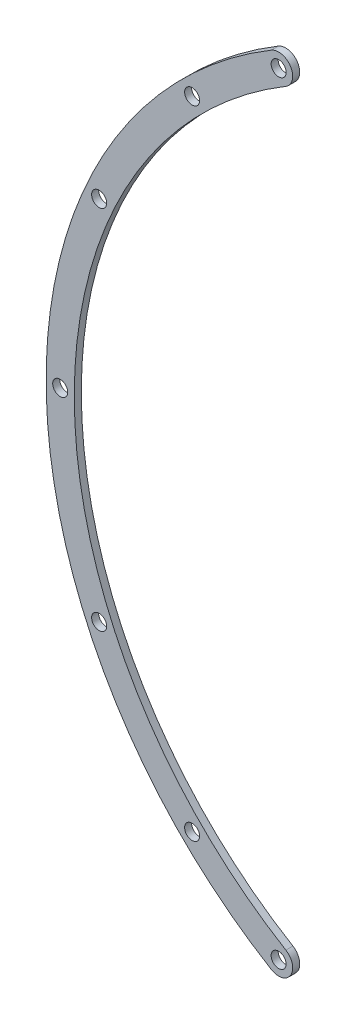
from build123d import *

# Parameters (mm, degrees)
SKETCH1_R            = 1.4
SKETCH1_R_2          = 1.6
SKETCH1_R_3          = 56
BOSS_EXTRUDE2_DEPTH  = 1.5
BOSS_EXTRUDE3_DEPTH  = 1.5
SKETCH3_R            = 1.6
CUT_EXTRUDE1_DEPTH   = 10
SKETCH4_R            = 1.6
BOSS_EXTRUDE4_DEPTH  = 1.5
FILLET1_R            = 3
SKETCH5_R            = 1.6
BOSS_EXTRUDE5_DEPTH  = 1.5
SKETCH6_R            = 1.6
CUT_EXTRUDE2_DEPTH   = 1.5
CUT_EXTRUDE3_DEPTH   = 10
SKETCH8_R            = 1.4
BOSS_EXTRUDE6_DEPTH  = 1.5
SKETCH9_W            = 144
SKETCH9_H            = 6
BOSS_EXTRUDE7_DEPTH  = 1.5
BOSS_EXTRUDE8_DEPTH  = 1.5
SKETCH11_W           = 71.777589622
SKETCH11_H           = 10.305965164
CUT_EXTRUDE4_DEPTH   = 41
SKETCH12_W           = 71.777589622
SKETCH12_H           = 6
BOSS_EXTRUDE9_DEPTH  = 1.5
SKETCH13_W           = 6
SKETCH13_H           = 51.475780146
SKETCH13_H_2         = 46.82423944
BOSS_EXTRUDE10_DEPTH = 1.5
SKETCH14_W           = 66
SKETCH14_H           = 6
CUT_EXTRUDE5_DEPTH   = 41
BOSS_EXTRUDE11_DEPTH = 1.5
SKETCH16_R           = 1.6
CUT_EXTRUDE6_DEPTH   = 5
SKETCH17_R           = 1.6
CUT_EXTRUDE7_DEPTH   = 5
SKETCH18_R           = 1.6
BOSS_EXTRUDE14_DEPTH = 1.5
BOSS_EXTRUDE15_DEPTH = 1.5
SKETCH21_W           = 1.5
SKETCH21_H           = 32.106154556
BOSS_EXTRUDE16_DEPTH = 1.5
SKETCH22_R           = 1.6
SKETCH22_R_2         = 1.7
CUT_EXTRUDE9_DEPTH   = 1.5
BOSS_EXTRUDE17_DEPTH = 1.5
SKETCH24_R           = 1.6
CUT_EXTRUDE10_DEPTH  = 1.5
SKETCH25_R           = 1.6
BOSS_EXTRUDE18_DEPTH = 1.5
SKETCH26_R           = 1.6
CUT_EXTRUDE11_DEPTH  = 1.5
SKETCH28_R           = 1.6
CUT_EXTRUDE12_DEPTH  = 1.5
SKETCH29_R           = 1.6
BOSS_EXTRUDE19_DEPTH = 1.5
SKETCH30_W           = 4.95
SKETCH30_H           = 32.106154556
SKETCH30_W_2         = 1.5
CUT_EXTRUDE13_DEPTH  = 1.5
BOSS_EXTRUDE20_DEPTH = 1.5
SKETCH32_R           = 1.6
BOSS_EXTRUDE21_DEPTH = 1.5
CUT_EXTRUDE14_DEPTH  = 10
SKETCH34_R           = 1.6
CUT_EXTRUDE15_DEPTH  = 10


with BuildPart() as part:
    # Sketch1 → Boss-Extrude2 (new body)
    with BuildSketch(Plane.XY):
        with BuildLine():
            Line((-35.888794811, 73.41211972), (-35.888794811, 92.265889727))
            ThreePointArc((-35.888794811, 92.265889727), (-42.061063674, 89.620683565), (-48.039811225, 86.563136135))
            Line((-48.039811225, 86.563136135), (-41.888794811, 80.41211972))
            Line((-41.888794811, 80.41211972), (-41.888794811, 65.59143593))
            Line((-41.888794811, 65.59143593), (-53.74011537, 53.74011537))
            Line((-53.74011537, 53.74011537), (-65.053823869, 42.426406871))
            Line((-65.053823869, 42.426406871), (-71.46564447, 36.01458627))
            Line((-71.46564447, 36.01458627), (-82.641648571, 47.190590371))
            ThreePointArc((-82.641648571, 47.190590371), (-85.206397148, 48.036317618), (-87.411811693, 46.477684716))
            ThreePointArc((-87.411811693, 46.477684716), (-99, 0), (-87.411811693, -46.477684716))
            ThreePointArc((-87.411811693, -46.477684716), (-85.206397148, -48.036317618), (-82.641648571, -47.190590371))
            Line((-82.641648571, -47.190590371), (-71.46564447, -36.01458627))
            Line((-71.46564447, -36.01458627), (-65.053823869, -42.426406871))
            Line((-65.053823869, -42.426406871), (-53.74011537, -53.74011537))
            Line((-53.74011537, -53.74011537), (-41.888794811, -65.59143593))
            Line((-41.888794811, -65.59143593), (-41.888794811, -80.41211972))
            Line((-41.888794811, -80.41211972), (-48.039811225, -86.563136135))
            ThreePointArc((-48.039811225, -86.563136135), (-42.061063674, -89.620683565), (-35.888794811, -92.265889727))
            Line((-35.888794811, -92.265889727), (-35.888794811, -73.41211972))
            Line((-35.888794811, -73.41211972), (35.888794811, -73.41211972))
            Line((35.888794811, -73.41211972), (35.888794811, -92.265889727))
            ThreePointArc((35.888794811, -92.265889727), (42.061063674, -89.620683565), (48.039811225, -86.563136135))
            Line((48.039811225, -86.563136135), (41.888794811, -80.41211972))
            Line((41.888794811, -80.41211972), (41.888794811, -65.59143593))
            Line((41.888794811, -65.59143593), (53.74011537, -53.74011537))
            Line((53.74011537, -53.74011537), (65.053823869, -42.426406871))
            Line((65.053823869, -42.426406871), (71.46564447, -36.01458627))
            Line((71.46564447, -36.01458627), (82.641648571, -47.190590371))
            ThreePointArc((82.641648571, -47.190590371), (85.206397148, -48.036317618), (87.411811693, -46.477684716))
            ThreePointArc((87.411811693, -46.477684716), (99, 0), (87.411811693, 46.477684716))
            ThreePointArc((87.411811693, 46.477684716), (85.206397148, 48.036317618), (82.641648571, 47.190590371))
            Line((82.641648571, 47.190590371), (71.46564447, 36.01458627))
            Line((71.46564447, 36.01458627), (65.053823869, 42.426406871))
            Line((65.053823869, 42.426406871), (53.74011537, 53.74011537))
            Line((53.74011537, 53.74011537), (41.888794811, 65.59143593))
            Line((41.888794811, 65.59143593), (41.888794811, 80.41211972))
            Line((41.888794811, 80.41211972), (48.039811225, 86.563136135))
            ThreePointArc((48.039811225, 86.563136135), (42.061063674, 89.620683565), (35.888794811, 92.265889727))
            Line((35.888794811, 92.265889727), (35.888794811, 73.41211972))
            Line((35.888794811, 73.41211972), (-35.888794811, 73.41211972))
        make_face()
        with Locations((-36.062445841, 54.447222151)):
            Circle(SKETCH1_R, mode=Mode.SUBTRACT)
        with Locations((-54.447222151, 36.062445841)):
            Circle(SKETCH1_R, mode=Mode.SUBTRACT)
        with Locations((-60.104076401, 41.71930009)):
            Circle(SKETCH1_R, mode=Mode.SUBTRACT)
        with Locations((-41.71930009, 60.104076401)):
            Circle(SKETCH1_R, mode=Mode.SUBTRACT)
        with Locations((41.365746699, 41.365746699)):
            Circle(SKETCH1_R_2, mode=Mode.SUBTRACT)
        with Locations((41.71930009, 60.104076401)):
            Circle(SKETCH1_R, mode=Mode.SUBTRACT)
        with Locations((60.104076401, 41.71930009)):
            Circle(SKETCH1_R, mode=Mode.SUBTRACT)
        with Locations((54.447222151, 36.062445841)):
            Circle(SKETCH1_R, mode=Mode.SUBTRACT)
        Circle(SKETCH1_R_3, mode=Mode.SUBTRACT)
        with Locations((36.062445841, 54.447222151)):
            Circle(SKETCH1_R, mode=Mode.SUBTRACT)
        with Locations((-40.571353127, 87.005547556)):
            Circle(SKETCH1_R_2, mode=Mode.SUBTRACT)
        with Locations((40.571353127, -87.005547556)):
            Circle(SKETCH1_R_2, mode=Mode.SUBTRACT)
        with Locations((-40.571353127, -87.005547556)):
            Circle(SKETCH1_R_2, mode=Mode.SUBTRACT)
        with Locations((41.365746699, -41.365746699)):
            Circle(SKETCH1_R_2, mode=Mode.SUBTRACT)
        with Locations((-41.365746699, 41.365746699)):
            Circle(SKETCH1_R_2, mode=Mode.SUBTRACT)
        with Locations((-84.762968914, 45.069270027)):
            Circle(SKETCH1_R_2, mode=Mode.SUBTRACT)
        with Locations((-41.365746699, -41.365746699)):
            Circle(SKETCH1_R_2, mode=Mode.SUBTRACT)
        with Locations((84.762968914, 45.069270027)):
            Circle(SKETCH1_R_2, mode=Mode.SUBTRACT)
        with Locations((40.571353127, 87.005547556)):
            Circle(SKETCH1_R_2, mode=Mode.SUBTRACT)
        with Locations((36.062445841, -54.447222151)):
            Circle(SKETCH1_R, mode=Mode.SUBTRACT)
        with Locations((54.447222151, -36.062445841)):
            Circle(SKETCH1_R, mode=Mode.SUBTRACT)
        with Locations((60.104076401, -41.71930009)):
            Circle(SKETCH1_R, mode=Mode.SUBTRACT)
        with Locations((41.71930009, -60.104076401)):
            Circle(SKETCH1_R, mode=Mode.SUBTRACT)
        with Locations((-41.71930009, -60.104076401)):
            Circle(SKETCH1_R, mode=Mode.SUBTRACT)
        with Locations((-60.104076401, -41.71930009)):
            Circle(SKETCH1_R, mode=Mode.SUBTRACT)
        with Locations((-54.447222151, -36.062445841)):
            Circle(SKETCH1_R, mode=Mode.SUBTRACT)
        with Locations((-36.062445841, -54.447222151)):
            Circle(SKETCH1_R, mode=Mode.SUBTRACT)
        with Locations((84.762968914, -45.069270027)):
            Circle(SKETCH1_R_2, mode=Mode.SUBTRACT)
        with Locations((-84.762968914, -45.069270027)):
            Circle(SKETCH1_R_2, mode=Mode.SUBTRACT)
        with BuildLine():
            Line((-56.568542495, 42.426406871), (-49.621038435, 35.478902811))
            ThreePointArc((-49.621038435, 35.478902811), (-43.133513652, 43.133513652), (-35.478902811, 49.621038435))
            Line((-35.478902811, 49.621038435), (-42.426406871, 56.568542495))
            Line((-42.426406871, 56.568542495), (-56.568542495, 42.426406871))
        make_face(mode=Mode.SUBTRACT)
        with BuildLine():
            Line((-57.337431152, 34.710014154), (-52.937019276, 30.309602278))
            ThreePointArc((-52.937019276, 30.309602278), (-61, 0), (-52.937019276, -30.309602278))
            Line((-52.937019276, -30.309602278), (-57.337431152, -34.710014154))
            Line((-57.337431152, -34.710014154), (-60.811183182, -38.183766184))
            Line((-60.811183182, -38.183766184), (-71.46564447, -27.529304896))
            Line((-71.46564447, -27.529304896), (-83.951228087, -40.014888513))
            ThreePointArc((-83.951228087, -40.014888513), (-93, 0), (-83.951228087, 40.014888513))
            Line((-83.951228087, 40.014888513), (-71.46564447, 27.529304896))
            Line((-71.46564447, 27.529304896), (-60.811183182, 38.183766184))
            Line((-60.811183182, 38.183766184), (-57.337431152, 34.710014154))
        make_face(mode=Mode.SUBTRACT)
        with BuildLine():
            Line((-35.888794811, 67.41211972), (-35.888794811, 58.516211808))
            Line((-35.888794811, 58.516211808), (-30.309602278, 52.937019275))
            ThreePointArc((-30.309602278, 52.937019275), (0, 61), (30.309602278, 52.937019275))
            Line((30.309602278, 52.937019275), (35.888794811, 58.516211808))
            Line((35.888794811, 58.516211808), (35.888794811, 67.41211972))
            Line((35.888794811, 67.41211972), (0, 67.41211972))
            Line((0, 67.41211972), (-35.888794811, 67.41211972))
        make_face(mode=Mode.SUBTRACT)
        with BuildLine():
            Line((60.811183182, 38.183766184), (71.46564447, 27.529304896))
            Line((71.46564447, 27.529304896), (83.951228087, 40.014888513))
            ThreePointArc((83.951228087, 40.014888513), (93, 0), (83.951228087, -40.014888513))
            Line((83.951228087, -40.014888513), (71.46564447, -27.529304896))
            Line((71.46564447, -27.529304896), (60.811183182, -38.183766184))
            Line((60.811183182, -38.183766184), (57.337431152, -34.710014154))
            Line((57.337431152, -34.710014154), (52.937019276, -30.309602278))
            ThreePointArc((52.937019276, -30.309602278), (61, 0), (52.937019276, 30.309602278))
            Line((52.937019276, 30.309602278), (57.337431152, 34.710014154))
            Line((57.337431152, 34.710014154), (60.811183182, 38.183766184))
        make_face(mode=Mode.SUBTRACT)
        with BuildLine():
            Line((42.426406871, 56.568542495), (56.568542495, 42.426406871))
            Line((56.568542495, 42.426406871), (49.621038435, 35.478902811))
            ThreePointArc((49.621038435, 35.478902811), (43.133513652, 43.133513652), (35.478902811, 49.621038435))
            Line((35.478902811, 49.621038435), (42.426406871, 56.568542495))
        make_face(mode=Mode.SUBTRACT)
        with BuildLine():
            Line((0, -67.41211972), (35.888794811, -67.41211972))
            Line((35.888794811, -67.41211972), (35.888794811, -58.516211808))
            Line((35.888794811, -58.516211808), (30.309602278, -52.937019275))
            ThreePointArc((30.309602278, -52.937019275), (0, -61), (-30.309602278, -52.937019275))
            Line((-30.309602278, -52.937019275), (-35.888794811, -58.516211808))
            Line((-35.888794811, -58.516211808), (-35.888794811, -67.41211972))
            Line((-35.888794811, -67.41211972), (0, -67.41211972))
        make_face(mode=Mode.SUBTRACT)
        with BuildLine():
            Line((56.568542495, -42.426406871), (49.621038435, -35.478902811))
            ThreePointArc((49.621038435, -35.478902811), (43.133513652, -43.133513652), (35.478902811, -49.621038435))
            Line((35.478902811, -49.621038435), (42.426406871, -56.568542495))
            Line((42.426406871, -56.568542495), (56.568542495, -42.426406871))
        make_face(mode=Mode.SUBTRACT)
        with BuildLine():
            Line((-42.426406871, -56.568542495), (-56.568542495, -42.426406871))
            Line((-56.568542495, -42.426406871), (-49.621038435, -35.478902811))
            ThreePointArc((-49.621038435, -35.478902811), (-43.133513652, -43.133513652), (-35.478902811, -49.621038435))
            Line((-35.478902811, -49.621038435), (-42.426406871, -56.568542495))
        make_face(mode=Mode.SUBTRACT)
    extrude(amount=BOSS_EXTRUDE2_DEPTH)

    # Sketch2 → Boss-Extrude3 (add)
    with BuildSketch(Plane.XY.offset(1.5)):
        with BuildLine():
            Line((-41.888794811, 80.41211972), (-41.888794811, 78.41211972))
            Line((-41.888794811, 78.41211972), (-49.31800671, 85.841331619))
            ThreePointArc((-49.31800671, 85.841331619), (-47.440229793, 86.893179233), (-45.540030314, 87.903956902))
            Line((-45.540030314, 87.903956902), (-41.888794811, 84.252721398))
            Line((-41.888794811, 84.252721398), (-41.888794811, 80.41211972))
        make_face()
        with BuildLine():
            Line((41.888794811, 84.252721398), (45.540030314, 87.903956902))
            ThreePointArc((45.540030314, 87.903956902), (47.440229793, 86.893179233), (49.31800671, 85.841331619))
            Line((49.31800671, 85.841331619), (41.888794811, 78.41211972))
            Line((41.888794811, 78.41211972), (41.888794811, 80.41211972))
            Line((41.888794811, 80.41211972), (41.888794811, 84.252721398))
        make_face()
        with BuildLine():
            Line((41.888794811, -80.41211972), (41.888794811, -78.41211972))
            Line((41.888794811, -78.41211972), (49.31800671, -85.841331619))
            ThreePointArc((49.31800671, -85.841331619), (47.440229793, -86.893179233), (45.540030314, -87.903956902))
            Line((45.540030314, -87.903956902), (41.888794811, -84.252721398))
            Line((41.888794811, -84.252721398), (41.888794811, -80.41211972))
        make_face()
        with BuildLine():
            Line((-41.888794811, -84.252721398), (-45.540030314, -87.903956902))
            ThreePointArc((-45.540030314, -87.903956902), (-47.440229793, -86.893179233), (-49.31800671, -85.841331619))
            Line((-49.31800671, -85.841331619), (-41.888794811, -78.41211972))
            Line((-41.888794811, -78.41211972), (-41.888794811, -80.41211972))
            Line((-41.888794811, -80.41211972), (-41.888794811, -84.252721398))
        make_face()
    extrude(amount=-BOSS_EXTRUDE3_DEPTH)

    # Sketch3 → Cut-Extrude1 (cut)
    with BuildSketch(Plane.XY.offset(1.5)):
        with Locations((-44.327866871, 85.153039985)):
            Circle(SKETCH3_R)
        with Locations((44.327866871, 85.153039985)):
            Circle(SKETCH3_R)
        with Locations((44.327866871, -85.153039985)):
            Circle(SKETCH3_R)
        with Locations((-44.327866871, -85.153039985)):
            Circle(SKETCH3_R)
    extrude(amount=-CUT_EXTRUDE1_DEPTH, mode=Mode.SUBTRACT)

    # Sketch4 → Boss-Extrude4 (add)
    with BuildSketch(Plane.XY.offset(1.5)):
        with Locations((-40.571353127, 87.005547556)):
            Circle(SKETCH4_R)
        with Locations((40.571353127, 87.005547556)):
            Circle(SKETCH4_R)
        with Locations((40.571353127, -87.005547556)):
            Circle(SKETCH4_R)
        with Locations((-40.571353127, -87.005547556)):
            Circle(SKETCH4_R)
    extrude(amount=-BOSS_EXTRUDE4_DEPTH)

    # Fillet1
    fillet1_edges = [part.edges().sort_by_distance(p)[0] for p in [
        (35.888794811, -92.265889727, 0.75),
        (-35.888794811, -92.265889727, 0.75),
        (-35.888794811, 92.265889727, 0.75),
        (35.888794811, 92.265889727, 0.75),
        (49.31800671, 85.841331619, 0.75),
        (-49.31800671, 85.841331619, 0.75),
        (49.31800671, -85.841331619, 0.75),
        (-49.31800671, -85.841331619, 0.75),
    ]]
    fillet(fillet1_edges, radius=FILLET1_R)

    # Sketch5 → Boss-Extrude5 (add)
    with BuildSketch(Plane.XY.offset(1.5)):
        with BuildLine():
            ThreePointArc((-7, 66.41211972), (-10, 63.41211972), (-13, 66.41211972))
            Line((-13, 66.41211972), (-13, 67.41211972))
            Line((-13, 67.41211972), (-9.775161328, 70.187281048))
            Line((-9.775161328, 70.187281048), (-7, 67.41211972))
            Line((-7, 67.41211972), (-7, 66.41211972))
        make_face()
        with Locations((-10, 66.41211972)):
            Circle(SKETCH5_R, mode=Mode.SUBTRACT)
        with BuildLine():
            Line((7, 66.41211972), (7, 67.41211972))
            Line((7, 67.41211972), (9.775161328, 70.187281048))
            Line((9.775161328, 70.187281048), (13, 67.41211972))
            Line((13, 67.41211972), (13, 66.41211972))
            ThreePointArc((13, 66.41211972), (10, 63.41211972), (7, 66.41211972))
        make_face()
        with Locations((10, 66.41211972)):
            Circle(SKETCH5_R, mode=Mode.SUBTRACT)
        with BuildLine():
            ThreePointArc((7, -66.41211972), (10, -63.41211972), (13, -66.41211972))
            Line((13, -66.41211972), (13, -67.41211972))
            Line((13, -67.41211972), (9.775161328, -70.187281048))
            Line((9.775161328, -70.187281048), (7, -67.41211972))
            Line((7, -67.41211972), (7, -66.41211972))
        make_face()
        with Locations((10, -66.41211972)):
            Circle(SKETCH5_R, mode=Mode.SUBTRACT)
        with BuildLine():
            Line((-7, -66.41211972), (-7, -67.41211972))
            Line((-7, -67.41211972), (-9.775161328, -70.187281048))
            Line((-9.775161328, -70.187281048), (-13, -67.41211972))
            Line((-13, -67.41211972), (-13, -66.41211972))
            ThreePointArc((-13, -66.41211972), (-10, -63.41211972), (-7, -66.41211972))
        make_face()
        with Locations((-10, -66.41211972)):
            Circle(SKETCH5_R, mode=Mode.SUBTRACT)
    extrude(amount=-BOSS_EXTRUDE5_DEPTH)

    # Sketch6 → Cut-Extrude2 (cut)
    with BuildSketch(Plane.XY.offset(1.5)):
        with Locations((-10, -66.41211972)):
            Circle(SKETCH6_R)
        with Locations((10, -66.41211972)):
            Circle(SKETCH6_R)
        with Locations((10, 66.41211972)):
            Circle(SKETCH6_R)
        with Locations((-10, 66.41211972)):
            Circle(SKETCH6_R)
    extrude(amount=-CUT_EXTRUDE2_DEPTH, mode=Mode.SUBTRACT)

    # Sketch7 → Cut-Extrude3 (cut)
    with BuildSketch(Plane.XY.offset(1.5)):
        Polygon((-71.46564447, 27.529304896), (-31.582829646, 67.41211972), (31.582829646, 67.41211972), (71.46564447, 27.529304896), (71.46564447, -27.529304896), (31.582829646, -67.41211972), (-31.582829646, -67.41211972), (-71.46564447, -27.529304896), align=None)
    extrude(amount=-CUT_EXTRUDE3_DEPTH, mode=Mode.SUBTRACT)

    # Sketch8 → Boss-Extrude6 (add)
    with BuildSketch(Plane.XY.offset(1.5)):
        with Locations((-60.104076401, -41.71930009)):
            Circle(SKETCH8_R)
        with Locations((-41.71930009, -60.104076401)):
            Circle(SKETCH8_R)
        with Locations((-60.104076401, 41.71930009)):
            Circle(SKETCH8_R)
        with Locations((-41.71930009, 60.104076401)):
            Circle(SKETCH8_R)
        with Locations((41.71930009, 60.104076401)):
            Circle(SKETCH8_R)
        with Locations((60.104076401, 41.71930009)):
            Circle(SKETCH8_R)
        with Locations((60.104076401, -41.71930009)):
            Circle(SKETCH8_R)
        with Locations((41.71930009, -60.104076401)):
            Circle(SKETCH8_R)
        Polygon((-23.568897205, -67.41211972), (23.568897205, -67.41211972), (18.047381119, -71.229666129), (-16.662853075, -71.229666129), align=None)
        Polygon((23.568897205, 67.41211972), (-26.29313108, 67.41211972), (-20.11587514, 71.683041123), (11.2489996, 71.683041123), align=None)
    extrude(amount=-BOSS_EXTRUDE6_DEPTH)

    # Sketch9 → Boss-Extrude7 (add)
    with BuildSketch(Plane.XY.offset(1.5)):
        with Locations((0, 26.41211972)):
            Rectangle(SKETCH9_W, SKETCH9_H)
        with Locations((0, -26.41211972)):
            Rectangle(SKETCH9_W, SKETCH9_H)
    extrude(amount=-BOSS_EXTRUDE7_DEPTH)

    # Sketch10 → Boss-Extrude8 (add)
    with BuildSketch(Plane.XY.offset(1.5)):
        Polygon((-72, 23.41211972), (-66, 23.41211972), (-66, 35.490217447), (-72, 28.063660426), align=None)
        Polygon((72, 28.063660426), (72, 23.41211972), (66, 23.41211972), (66, 35.490217447), align=None)
        Polygon((72, -23.41211972), (66, -23.41211972), (66, -35.490217447), (72, -28.063660426), align=None)
        Polygon((-72, -28.063660426), (-72, -23.41211972), (-66, -23.41211972), (-66, -35.490217447), align=None)
    extrude(amount=-BOSS_EXTRUDE8_DEPTH)

    # Sketch11 → Cut-Extrude4 (cut)
    with BuildSketch(Plane.XY.offset(1.5)):
        with Locations((0, 68.259137138)):
            Rectangle(SKETCH11_W, SKETCH11_H)
        with Locations((0, -68.259137138)):
            Rectangle(SKETCH11_W, SKETCH11_H)
    extrude(amount=-CUT_EXTRUDE4_DEPTH, mode=Mode.SUBTRACT)

    # Sketch12 → Boss-Extrude9 (add)
    with BuildSketch(Plane.XY.offset(1.5)):
        with Locations((0, 66.106154556)):
            Rectangle(SKETCH12_W, SKETCH12_H)
        with Locations((0, -66.106154556)):
            Rectangle(SKETCH12_W, SKETCH12_H)
    extrude(amount=-BOSS_EXTRUDE9_DEPTH)

    # Sketch13 → Boss-Extrude10 (add)
    with BuildSketch(Plane.XY.offset(1.5)):
        with Locations((-69, -2.325770353)):
            Rectangle(SKETCH13_W, SKETCH13_H)
        with Locations((69, 0)):
            Rectangle(SKETCH13_W, SKETCH13_H_2)
    extrude(amount=-BOSS_EXTRUDE10_DEPTH)

    # Sketch14 → Cut-Extrude5 (cut)
    with BuildSketch(Plane.XY.offset(1.5)):
        with Locations((33, 26.41211972)):
            Rectangle(SKETCH14_W, SKETCH14_H)
        with Locations((-33, 26.41211972)):
            Rectangle(SKETCH14_W, SKETCH14_H)
        with Locations((-33, -26.41211972)):
            Rectangle(SKETCH14_W, SKETCH14_H)
        with Locations((33, -26.41211972)):
            Rectangle(SKETCH14_W, SKETCH14_H)
    extrude(amount=-CUT_EXTRUDE5_DEPTH, mode=Mode.SUBTRACT)

    # Sketch15 → Boss-Extrude11 (add)
    with BuildSketch(Plane.XY.offset(1.5)):
        Polygon((-66, -25), (0, -25), (66, -25), (66, -31), (-66, -31), align=None)
        Polygon((0, 25), (66, 25), (66, 31), (-66, 31), (-66, 25), align=None)
    extrude(amount=-BOSS_EXTRUDE11_DEPTH)

    # Sketch16 → Cut-Extrude6 (cut)
    with BuildSketch(Plane.XY.offset(1.5)):
        with Locations((60, 28)):
            Circle(SKETCH16_R)
        with Locations((-60, 28)):
            Circle(SKETCH16_R)
        with Locations((-60, -28)):
            Circle(SKETCH16_R)
        with Locations((60, -28)):
            Circle(SKETCH16_R)
    extrude(amount=-CUT_EXTRUDE6_DEPTH, mode=Mode.SUBTRACT)

    # Sketch17 → Cut-Extrude7 (cut)
    with BuildSketch(Plane.XY.offset(1.5)):
        with Locations((-40, 28)):
            Circle(SKETCH17_R)
        with Locations((40, 28)):
            Circle(SKETCH17_R)
        with Locations((40, -28)):
            Circle(SKETCH17_R)
        with Locations((-40, -28)):
            Circle(SKETCH17_R)
    extrude(amount=-CUT_EXTRUDE7_DEPTH, mode=Mode.SUBTRACT)

    # Sketch18 → Boss-Extrude14 (add)
    with BuildSketch(Plane.XY.offset(1.5)):
        Polygon((34.5, 63.106154556), (34.5, 31), (31.5, 31), (28.5, 31), (28.5, 63.106154556), align=None)
        with Locations((31.5, 49)):
            Circle(SKETCH18_R, mode=Mode.SUBTRACT)
        with Locations((31.5, 39)):
            Circle(SKETCH18_R, mode=Mode.SUBTRACT)
        Polygon((-34.5, -63.106154556), (-34.5, -31), (-31.5, -31), (-28.5, -31), (-28.5, -63.106154556), align=None)
        with Locations((-31.5, -49)):
            Circle(SKETCH18_R, mode=Mode.SUBTRACT)
        with Locations((-31.5, -39)):
            Circle(SKETCH18_R, mode=Mode.SUBTRACT)
    extrude(amount=-BOSS_EXTRUDE14_DEPTH)

    # Sketch19 → Boss-Extrude15 (add)
    with BuildSketch(Plane.XY.offset(1.5)):
        Polygon((-38, 31), (-35, 31), (-35, 63.106154556), (-35.888794811, 63.106154556), (-41, 57.994949366), (-41, 31), align=None)
        with BuildLine():
            ThreePointArc((-36.4, 39), (-36.86862915, 37.86862915), (-38, 37.4))
            ThreePointArc((-38, 37.4), (-39.6, 39), (-38, 40.6))
            ThreePointArc((-38, 40.6), (-36.86862915, 40.13137085), (-36.4, 39))
        make_face(mode=Mode.SUBTRACT)
        with BuildLine():
            ThreePointArc((-36.4, 49), (-36.86862915, 47.86862915), (-38, 47.4))
            ThreePointArc((-38, 47.4), (-39.13137085, 50.13137085), (-36.4, 49))
        make_face(mode=Mode.SUBTRACT)
        Polygon((38, -31), (35, -31), (35, -63.106154556), (35.888794811, -63.106154556), (41, -57.994949366), (41, -31), align=None)
        with BuildLine():
            ThreePointArc((39.6, -49), (36.86862915, -50.13137085), (38, -47.4))
            ThreePointArc((38, -47.4), (39.13137085, -47.86862915), (39.6, -49))
        make_face(mode=Mode.SUBTRACT)
        with BuildLine():
            ThreePointArc((38, -40.6), (36.4, -39), (38, -37.4))
            ThreePointArc((38, -37.4), (39.13137085, -37.86862915), (39.6, -39))
            ThreePointArc((39.6, -39), (39.13137085, -40.13137085), (38, -40.6))
        make_face(mode=Mode.SUBTRACT)
    extrude(amount=-BOSS_EXTRUDE15_DEPTH)

    # Sketch21 → Boss-Extrude16 (add)
    with BuildSketch(Plane.XY.offset(1.5)):
        with BuildLine():
            ThreePointArc((-32.25, -40.413329403), (-31.4, -39), (-32.25, -37.586670597))
            ThreePointArc((-32.25, -37.586670597), (-29.9, -39), (-32.25, -40.413329403))
        make_face()
        with BuildLine():
            ThreePointArc((-32.25, -50.413329403), (-31.4, -49), (-32.25, -47.586670597))
            ThreePointArc((-32.25, -47.586670597), (-29.9, -49), (-32.25, -50.413329403))
        make_face()
        with Locations((-35.25, -47.053077278)):
            Rectangle(SKETCH21_W, SKETCH21_H)
        Polygon((42.5, -56.494949366), (41, -57.994949366), (41, -31), (42.5, -31), align=None)
        with BuildLine():
            ThreePointArc((38.75, -50.413329403), (36.4, -49), (38.75, -47.586670597))
            ThreePointArc((38.75, -47.586670597), (37.9, -49), (38.75, -50.413329403))
        make_face()
        with BuildLine():
            ThreePointArc((38.75, -40.413329403), (36.4, -39), (38.75, -37.586670597))
            ThreePointArc((38.75, -37.586670597), (37.9, -39), (38.75, -40.413329403))
        make_face()
        with Locations((35.25, 47.053077278)):
            Rectangle(SKETCH21_W, SKETCH21_H)
        with BuildLine():
            ThreePointArc((32.25, 47.586670597), (29.9, 49), (32.25, 50.413329403))
            ThreePointArc((32.25, 50.413329403), (31.4, 49), (32.25, 47.586670597))
        make_face()
        with BuildLine():
            ThreePointArc((32.25, 37.586670597), (29.9, 39), (32.25, 40.413329403))
            ThreePointArc((32.25, 40.413329403), (31.4, 39), (32.25, 37.586670597))
        make_face()
        with BuildLine():
            ThreePointArc((-38.75, 47.586670597), (-37.9, 49), (-38.75, 50.413329403))
            ThreePointArc((-38.75, 50.413329403), (-36.4, 49), (-38.75, 47.586670597))
        make_face()
        with BuildLine():
            ThreePointArc((-38.75, 37.586670597), (-37.9, 39), (-38.75, 40.413329403))
            ThreePointArc((-38.75, 40.413329403), (-36.4, 39), (-38.75, 37.586670597))
        make_face()
        Polygon((-41, 57.994949366), (-41, 31), (-42.5, 31), (-42.5, 56.494949366), align=None)
    extrude(amount=-BOSS_EXTRUDE16_DEPTH)

    # Sketch22 → Cut-Extrude9 (cut)
    with BuildSketch(Plane.XY.offset(1.5)):
        with Locations((-39.5, 49)):
            Circle(SKETCH22_R)
        with Locations((-39.6, 39)):
            Circle(SKETCH22_R_2)
        with Locations((33, 49)):
            Circle(SKETCH22_R)
        with Locations((33, 39)):
            Circle(SKETCH22_R)
        with Locations((-33, -39)):
            Circle(SKETCH22_R)
        with Locations((-33, -49)):
            Circle(SKETCH22_R)
        with Locations((39.5, -39)):
            Circle(SKETCH22_R)
        with Locations((39.5, -49)):
            Circle(SKETCH22_R)
    extrude(amount=-CUT_EXTRUDE9_DEPTH, mode=Mode.SUBTRACT)

    # Sketch23 → Boss-Extrude17 (add)
    with BuildSketch(Plane.XY.offset(1.5)):
        Polygon((36, 31), (39.45, 31), (39.45, 59.544949366), (36, 62.994949366), align=None)
        Polygon((-36, -31), (-39.45, -31), (-39.45, -59.544949366), (-36, -62.994949366), align=None)
    extrude(amount=-BOSS_EXTRUDE17_DEPTH)

    # Sketch24 → Cut-Extrude10 (cut)
    with BuildSketch(Plane.XY.offset(1.5)):
        with Locations((-36.45, -49)):
            Circle(SKETCH24_R)
        with Locations((-36.45, -39)):
            Circle(SKETCH24_R)
        with Locations((36.45, 49)):
            Circle(SKETCH24_R)
        with Locations((36.45, 39)):
            Circle(SKETCH24_R)
    extrude(amount=-CUT_EXTRUDE10_DEPTH, mode=Mode.SUBTRACT)

    # Sketch25 → Boss-Extrude18 (add)
    with BuildSketch(Plane.XY.offset(1.5)):
        with BuildLine():
            Line((-93.258777892, -26.525048498), (-91.439555948, -32.242603178))
            Line((-91.439555948, -32.242603178), (-87.090389028, -30.85877734))
            ThreePointArc((-87.090389028, -30.85877734), (-85.14122266, -27.090389028), (-88.909610972, -25.14122266))
            Line((-88.909610972, -25.14122266), (-93.258777892, -26.525048498))
        make_face()
        with Locations((-88, -28)):
            Circle(SKETCH25_R, mode=Mode.SUBTRACT)
        with BuildLine():
            Line((-87.090389028, 30.85877734), (-91.439555948, 32.242603178))
            Line((-91.439555948, 32.242603178), (-93.258777892, 26.525048498))
            Line((-93.258777892, 26.525048498), (-88.909610972, 25.14122266))
            ThreePointArc((-88.909610972, 25.14122266), (-85.14122266, 27.090389028), (-87.090389028, 30.85877734))
        make_face()
        with Locations((-88, 28)):
            Circle(SKETCH25_R, mode=Mode.SUBTRACT)
        with BuildLine():
            Line((87.090389028, -30.85877734), (91.439555948, -32.242603178))
            Line((91.439555948, -32.242603178), (93.258777892, -26.525048498))
            Line((93.258777892, -26.525048498), (88.909610972, -25.14122266))
            ThreePointArc((88.909610972, -25.14122266), (85.14122266, -27.090389028), (87.090389028, -30.85877734))
        make_face()
        with Locations((88, -28)):
            Circle(SKETCH25_R, mode=Mode.SUBTRACT)
        with BuildLine():
            Line((93.258777892, 26.525048498), (91.439555948, 32.242603178))
            Line((91.439555948, 32.242603178), (87.090389028, 30.85877734))
            ThreePointArc((87.090389028, 30.85877734), (85.14122266, 27.090389028), (88.909610972, 25.14122266))
            Line((88.909610972, 25.14122266), (93.258777892, 26.525048498))
        make_face()
        with Locations((88, 28)):
            Circle(SKETCH25_R, mode=Mode.SUBTRACT)
    extrude(amount=-BOSS_EXTRUDE18_DEPTH)

    # Sketch26 → Cut-Extrude11 (cut)
    with BuildSketch(Plane.XY.offset(1.5)):
        with Locations((-88, 28)):
            Circle(SKETCH26_R)
        with Locations((-88, -28)):
            Circle(SKETCH26_R)
        with Locations((88, -28)):
            Circle(SKETCH26_R)
        with Locations((88, 28)):
            Circle(SKETCH26_R)
    extrude(amount=-CUT_EXTRUDE11_DEPTH, mode=Mode.SUBTRACT)

    # Sketch28 → Cut-Extrude12 (cut)
    with BuildSketch(Plane.XY.offset(1.5)):
        with Locations((-87.700363934, 39.046717735)):
            Circle(SKETCH28_R)
        with Locations((87.700363934, 39.046717735)):
            Circle(SKETCH28_R)
        with Locations((87.700363934, -39.046717735)):
            Circle(SKETCH28_R)
        with Locations((-87.700363934, -39.046717735)):
            Circle(SKETCH28_R)
    extrude(amount=-CUT_EXTRUDE12_DEPTH, mode=Mode.SUBTRACT)

    # Sketch29 → Boss-Extrude19 (add)
    with BuildSketch(Plane.XY.offset(1.5)):
        with BuildLine():
            Line((42.598378746, 89.366538079), (38.032036127, 79.786872289))
            Line((38.032036127, 79.786872289), (41.393256923, 64.252993798))
            Line((41.393256923, 64.252993798), (46.575002765, 72.29639768))
            Line((46.575002765, 72.29639768), (51.939928592, 80.62414407))
            Line((51.939928592, 80.62414407), (51.990700761, 80.70295555))
            ThreePointArc((51.990700761, 80.70295555), (52.360123748, 82.991062404), (50.988769416, 84.85956277))
            ThreePointArc((50.988769416, 84.85956277), (46.847804451, 87.214008153), (42.598378746, 89.366538079))
        make_face()
        with Locations((44.327866871, 85.153039985)):
            Circle(SKETCH29_R, mode=Mode.SUBTRACT)
        with Locations((49.443655191, 82.288060867)):
            Circle(SKETCH29_R, mode=Mode.SUBTRACT)
        with BuildLine():
            ThreePointArc((-50.988769416, 84.85956277), (-52.360123748, 82.991062404), (-51.990700761, 80.70295555))
            Line((-51.990700761, 80.70295555), (-51.939928592, 80.62414407))
            Line((-51.939928592, 80.62414407), (-46.575002765, 72.29639768))
            Line((-46.575002765, 72.29639768), (-41.393256923, 64.252993798))
            Line((-41.393256923, 64.252993798), (-38.032036127, 79.786872289))
            Line((-38.032036127, 79.786872289), (-42.598378746, 89.366538079))
            ThreePointArc((-42.598378746, 89.366538079), (-46.847804451, 87.214008153), (-50.988769416, 84.85956277))
        make_face()
        with Locations((-49.443655191, 82.288060867)):
            Circle(SKETCH29_R, mode=Mode.SUBTRACT)
        with Locations((-44.327866871, 85.153039985)):
            Circle(SKETCH29_R, mode=Mode.SUBTRACT)
        with BuildLine():
            Line((-42.598378746, -89.366538079), (-38.032036127, -79.786872289))
            Line((-38.032036127, -79.786872289), (-41.393256923, -64.252993798))
            Line((-41.393256923, -64.252993798), (-46.575002765, -72.29639768))
            Line((-46.575002765, -72.29639768), (-51.939928592, -80.62414407))
            Line((-51.939928592, -80.62414407), (-51.990700761, -80.70295555))
            ThreePointArc((-51.990700761, -80.70295555), (-52.360123748, -82.991062404), (-50.988769416, -84.85956277))
            ThreePointArc((-50.988769416, -84.85956277), (-46.847804451, -87.214008153), (-42.598378746, -89.366538079))
        make_face()
        with Locations((-49.443655191, -82.288060867)):
            Circle(SKETCH29_R, mode=Mode.SUBTRACT)
        with Locations((-44.327866871, -85.153039985)):
            Circle(SKETCH29_R, mode=Mode.SUBTRACT)
        with BuildLine():
            ThreePointArc((50.988769416, -84.85956277), (52.360123748, -82.991062404), (51.990700761, -80.70295555))
            Line((51.990700761, -80.70295555), (51.939928592, -80.62414407))
            Line((51.939928592, -80.62414407), (46.575002765, -72.29639768))
            Line((46.575002765, -72.29639768), (41.393256923, -64.252993798))
            Line((41.393256923, -64.252993798), (38.032036127, -79.786872289))
            Line((38.032036127, -79.786872289), (42.598378746, -89.366538079))
            ThreePointArc((42.598378746, -89.366538079), (46.847804451, -87.214008153), (50.988769416, -84.85956277))
        make_face()
        with Locations((44.327866871, -85.153039985)):
            Circle(SKETCH29_R, mode=Mode.SUBTRACT)
        with Locations((49.443655191, -82.288060867)):
            Circle(SKETCH29_R, mode=Mode.SUBTRACT)
    extrude(amount=-BOSS_EXTRUDE19_DEPTH)

    # Sketch30 → Cut-Extrude13 (cut)
    with BuildSketch(Plane.XY.offset(1.5)):
        with Locations((-30.975, -47.053077278)):
            Rectangle(SKETCH30_W, SKETCH30_H)
        with Locations((35.75, -47.053077278)):
            Rectangle(SKETCH30_W_2, SKETCH30_H)
        with Locations((-35.75, 47.053077278)):
            Rectangle(SKETCH30_W_2, SKETCH30_H)
        with Locations((30.975, 47.053077278)):
            Rectangle(SKETCH30_W, SKETCH30_H)
    extrude(amount=-CUT_EXTRUDE13_DEPTH, mode=Mode.SUBTRACT)

    # Sketch31 → Boss-Extrude20 (add)
    with BuildSketch(Plane.XY.offset(1.5)):
        Polygon((-33.45, -37.464584747), (-33.45, -54.487199965), (-35.24979153, -54.197542826), (-34.606108999, -47.664165134), (-34.927950264, -41.098603317), (-34.516917919, -36.926625012), align=None)
        Polygon((34.796478965, 51.236898102), (34.796478965, 47.17274868), (34.796478965, 35.517074868), (33.45, 32.015260587), (33.45, 51.901475994), align=None)
    extrude(amount=-BOSS_EXTRUDE20_DEPTH)

    # Sketch32 → Boss-Extrude21 (add)
    with BuildSketch(Plane.XY.offset(1.5)):
        with BuildLine():
            ThreePointArc((-47.898540967, 79.716558965), (-46.872153289, 83.833175092), (-50.988769416, 84.85956277))
            ThreePointArc((-50.988769416, 84.85956277), (-99, 0), (-50.988769416, -84.85956277))
            ThreePointArc((-50.988769416, -84.85956277), (-46.872153289, -83.833175092), (-47.898540967, -79.716558965))
            ThreePointArc((-47.898540967, -79.716558965), (-93, 0), (-47.898540967, 79.716558965))
        make_face()
        with Locations((-87.700363934, -39.046717735)):
            Circle(SKETCH32_R, mode=Mode.SUBTRACT)
        with Locations((-87.700363934, 39.046717735)):
            Circle(SKETCH32_R, mode=Mode.SUBTRACT)
        with Locations((-49.443655191, 82.288060867)):
            Circle(SKETCH32_R, mode=Mode.SUBTRACT)
        with Locations((-49.443655191, -82.288060867)):
            Circle(SKETCH32_R, mode=Mode.SUBTRACT)
    extrude(amount=-BOSS_EXTRUDE21_DEPTH)

    # Sketch33 → Cut-Extrude14 (cut)
    with BuildSketch(Plane.XY.offset(1.5)):
        with BuildLine():
            ThreePointArc((-47.898540967, 79.716558965), (-93, 0), (-47.898540967, -79.716558965))
            ThreePointArc((-47.898540967, -79.716558965), (-46.872153289, -83.833175092), (-50.988769416, -84.85956277))
            ThreePointArc((-50.988769416, -84.85956277), (99, 0), (-50.988769416, 84.85956277))
            ThreePointArc((-50.988769416, 84.85956277), (-46.872153289, 83.833175092), (-47.898540967, 79.716558965))
        make_face()
    extrude(amount=-CUT_EXTRUDE14_DEPTH, mode=Mode.SUBTRACT)

    # Sketch34 → Cut-Extrude15 (cut)
    with BuildSketch(Plane.XY.offset(1.5)):
        with Locations((-67.882250994, 67.882250994)):
            Circle(SKETCH34_R)
        with Locations((-96, 0)):
            Circle(SKETCH34_R)
        with Locations((-67.882250994, -67.882250994)):
            Circle(SKETCH34_R)
    extrude(amount=-CUT_EXTRUDE15_DEPTH, mode=Mode.SUBTRACT)


solid = part.part
